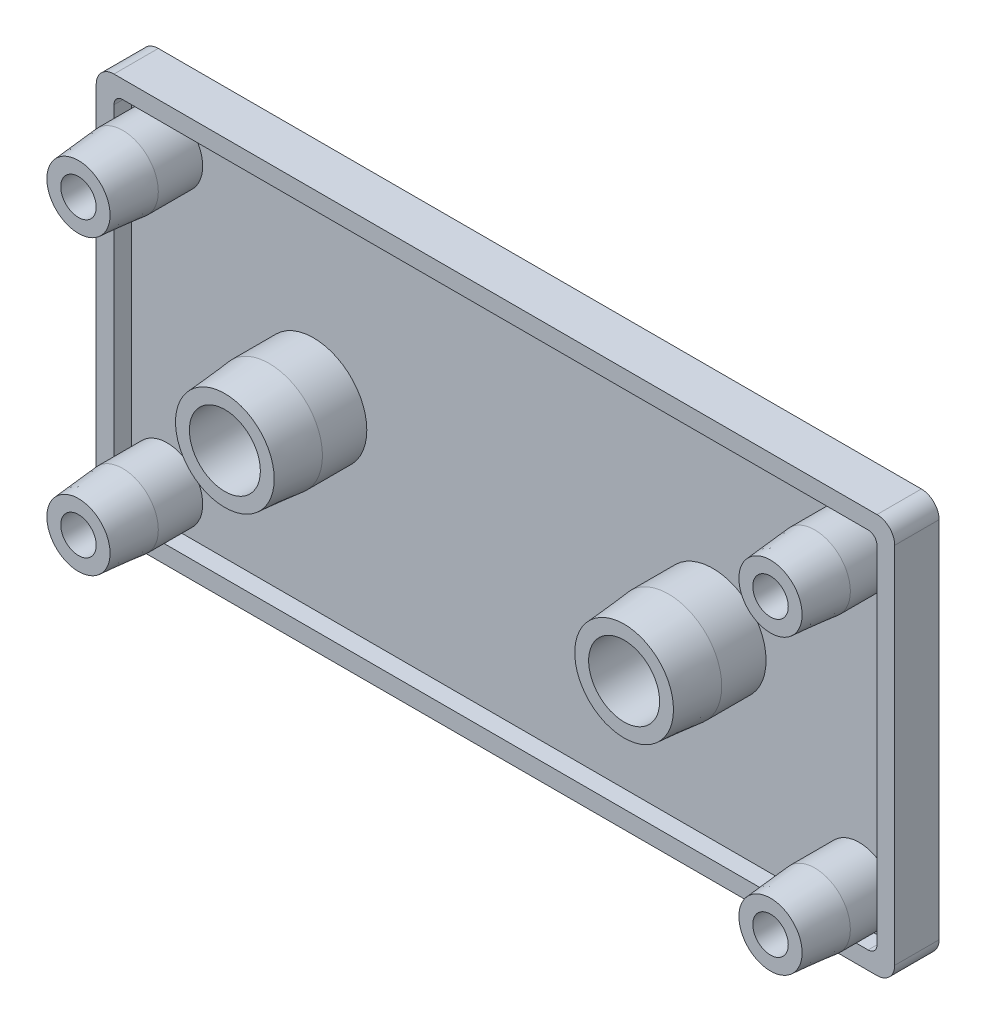
from build123d import *

# Parameters (mm, degrees)
EXTRUDE_1_DEPTH                     = 5
CUT_EXTRUDE_2_DEPTH                 = 2
SKETCH_2_R                          = 4
SKETCH_2_R_2                        = 2
EXTRUDE_2_DEPTH                     = 10
CHAMFER_1_SIZE                      = 5
CHAMFER_1_SIZE2                     = 0.437443318
PATTERN_LINEAR_3_COUNT              = 2
PATTERN_LINEAR_3_PITCH              = 78
PATTERN_LINEAR_3_2_COUNT            = 2
PATTERN_LINEAR_3_2_PITCH            = 33
SKETCH_3_R                          = 6
SKETCH_3_R_2                        = 4
EXTRUDE_3_DEPTH                     = 10
CHAMFER_2_SIZE                      = 5
CHAMFER_2_SIZE2                     = 0.437443318
PATTERN_LINEAR_4_COUNT              = 2
PATTERN_LINEAR_4_PITCH              = 45
CHAMFER_2_OF_PATTERN_LINEAR_4_SIZE2 = 0.437443318
CHAMFER_2_OF_PATTERN_LINEAR_4_SIZE  = 5


with BuildPart() as part:
    # Sketch 1 → Extrude 1 (new body)
    with BuildSketch(Plane.XY):
        with BuildLine():
            Line((958.366859686, 542.581000178), (872.366859686, 542.581000178))
            ThreePointArc((872.366859686, 542.581000178), (870.952646124, 543.166786616), (870.366859686, 544.581000178))
            Line((870.366859686, 544.581000178), (870.366859686, 585.581000178))
            ThreePointArc((870.366859686, 585.581000178), (870.952646124, 586.995213741), (872.366859686, 587.581000178))
            Line((872.366859686, 587.581000178), (958.366859686, 587.581000178))
            ThreePointArc((958.366859686, 587.581000178), (959.781073249, 586.995213741), (960.366859686, 585.581000178))
            Line((960.366859686, 585.581000178), (960.366859686, 544.581000178))
            ThreePointArc((960.366859686, 544.581000178), (959.781073249, 543.166786616), (958.366859686, 542.581000178))
        make_face()
    extrude(amount=-EXTRUDE_1_DEPTH)

    # Sketch 1_4 → Cut-Extrude 2 (cut)
    with BuildSketch(Plane.XY):
        with BuildLine():
            Line((876.366859686, 544.581000178), (954.366859686, 544.581000178))
            Line((954.366859686, 544.581000178), (957.366859686, 544.581000178))
            ThreePointArc((957.366859686, 544.581000178), (958.073966467, 544.873893397), (958.366859686, 545.581000178))
            Line((958.366859686, 545.581000178), (958.366859686, 548.581000178))
            Line((958.366859686, 548.581000178), (958.366859686, 581.581000178))
            Line((958.366859686, 581.581000178), (958.366859686, 584.581000178))
            ThreePointArc((958.366859686, 584.581000178), (958.073966467, 585.288106959), (957.366859686, 585.581000178))
            Line((957.366859686, 585.581000178), (954.366859686, 585.581000178))
            Line((954.366859686, 585.581000178), (876.366859686, 585.581000178))
            Line((876.366859686, 585.581000178), (873.366859686, 585.581000178))
            ThreePointArc((873.366859686, 585.581000178), (872.659752905, 585.288106959), (872.366859686, 584.581000178))
            Line((872.366859686, 584.581000178), (872.366859686, 581.581000178))
            Line((872.366859686, 581.581000178), (872.366859686, 548.581000178))
            Line((872.366859686, 548.581000178), (872.366859686, 545.581000178))
            ThreePointArc((872.366859686, 545.581000178), (872.659752905, 544.873893397), (873.366859686, 544.581000178))
            Line((873.366859686, 544.581000178), (876.366859686, 544.581000178))
        make_face()
    extrude(amount=-CUT_EXTRUDE_2_DEPTH, mode=Mode.SUBTRACT)

    # Sketch 3 → Extrude 3 (add)
    with BuildSketch(Plane.XY.offset(-2)):
        with Locations((937.866859686, 565.081000178)):
            Circle(SKETCH_3_R)
        with Locations((937.866859686, 565.081000178)):
            Circle(SKETCH_3_R_2, mode=Mode.SUBTRACT)
    extrude_3 = extrude(amount=EXTRUDE_3_DEPTH)

    # Chamfer 2
    chamfer_2_edges = [part.edges().sort_by_distance(p)[0] for p in [
        (931.866859686, 565.081000178, 8),
    ]]
    chamfer_2_side = [part.faces().sort_by_distance(p)[0] for p in [
        (931.866859686, 565.081000178, 3),
    ]]
    chamfer(chamfer_2_edges, length=CHAMFER_2_SIZE, length2=CHAMFER_2_SIZE2, reference=chamfer_2_side[0])

    # Pattern Linear 4: Extrude 3 ×2
    with Locations(*[(-i * PATTERN_LINEAR_4_PITCH, 0, 0) for i in range(1, PATTERN_LINEAR_4_COUNT)]):
        add(extrude_3)

    # Chamfer 2 of Pattern Linear 4
    chamfer_2_of_pattern_linear_4_edges = [part.edges().sort_by_distance(p)[0] for p in [
        (886.866859686, 565.081000178, 8),
    ]]
    chamfer(chamfer_2_of_pattern_linear_4_edges, length=CHAMFER_2_OF_PATTERN_LINEAR_4_SIZE, length2=CHAMFER_2_OF_PATTERN_LINEAR_4_SIZE2)


with BuildPart() as body_2:
    # Sketch 2 → Extrude 2 (new body)
    with BuildSketch(Plane.XY.offset(-2)):
        with Locations((954.366859686, 581.581000178)):
            Circle(SKETCH_2_R)
        with Locations((954.366859686, 581.581000178)):
            Circle(SKETCH_2_R_2, mode=Mode.SUBTRACT)
    extrude(amount=EXTRUDE_2_DEPTH)

    # Chamfer 1
    chamfer_1_edges = [body_2.edges().sort_by_distance(p)[0] for p in [
        (950.366859686, 581.581000178, 8),
    ]]
    chamfer_1_side = [body_2.faces().sort_by_distance(p)[0] for p in [
        (950.366859686, 581.581000178, 3),
    ]]
    chamfer(chamfer_1_edges, length=CHAMFER_1_SIZE, length2=CHAMFER_1_SIZE2, reference=chamfer_1_side[0])


with BuildPart() as pattern_linear_3_1:
    # Pattern Linear 3: pattern copy
    add(body_2.part.moved(Location(Vector(-1, 0, 0) * (1 * PATTERN_LINEAR_3_PITCH))))


with BuildPart() as pattern_linear_3_2_1:
    # Pattern Linear 3 2: pattern copy
    add(body_2.part.moved(Location(Vector(0, -1, 0) * (1 * PATTERN_LINEAR_3_2_PITCH))))


with BuildPart() as pattern_linear_3_2_2:
    # Pattern Linear 3 2: pattern copy
    add(pattern_linear_3_1.part.moved(Location(Vector(0, -1, 0) * (1 * PATTERN_LINEAR_3_2_PITCH))))


solid = Compound([part.part, body_2.part, pattern_linear_3_1.part, pattern_linear_3_2_1.part, pattern_linear_3_2_2.part])
